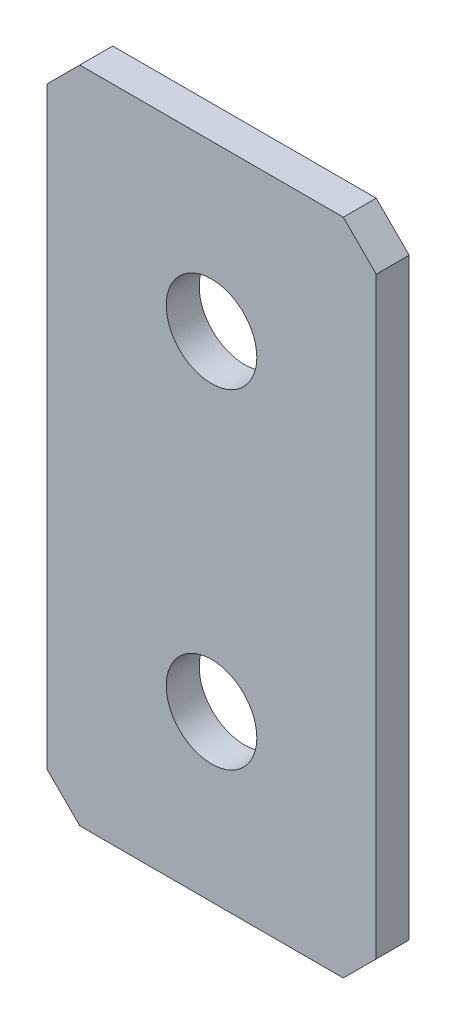
from build123d import *

# Parameters (mm, degrees)
SKETCH_1_W        = 20
SKETCH_1_H        = 40
EXTRUDE_1_DEPTH   = 2
CHAMFER_1_SIZE    = 2
HOLE_WIZARD_M51_D = 5.5


with BuildPart() as part:
    # Эскиз1 → Бобышка-Вытянуть1 (new body)
    with BuildSketch(Plane.XY):
        Rectangle(SKETCH_1_W, SKETCH_1_H)
    extrude(amount=EXTRUDE_1_DEPTH)

    # Фаска1
    chamfer_1_edges = [part.edges().sort_by_distance(p)[0] for p in [
        (10, -20, 1),
        (-10, -20, 1),
        (-10, 20, 1),
        (10, 20, 1),
    ]]
    chamfer(chamfer_1_edges, length=CHAMFER_1_SIZE)

    # Отверстие с зазором M51 (through all)
    with Locations(Plane.XY.offset(2)):
        with Locations((0, -30), (0, 30), (0, 10), (0, -10)):
            Hole(HOLE_WIZARD_M51_D / 2)


solid = part.part
